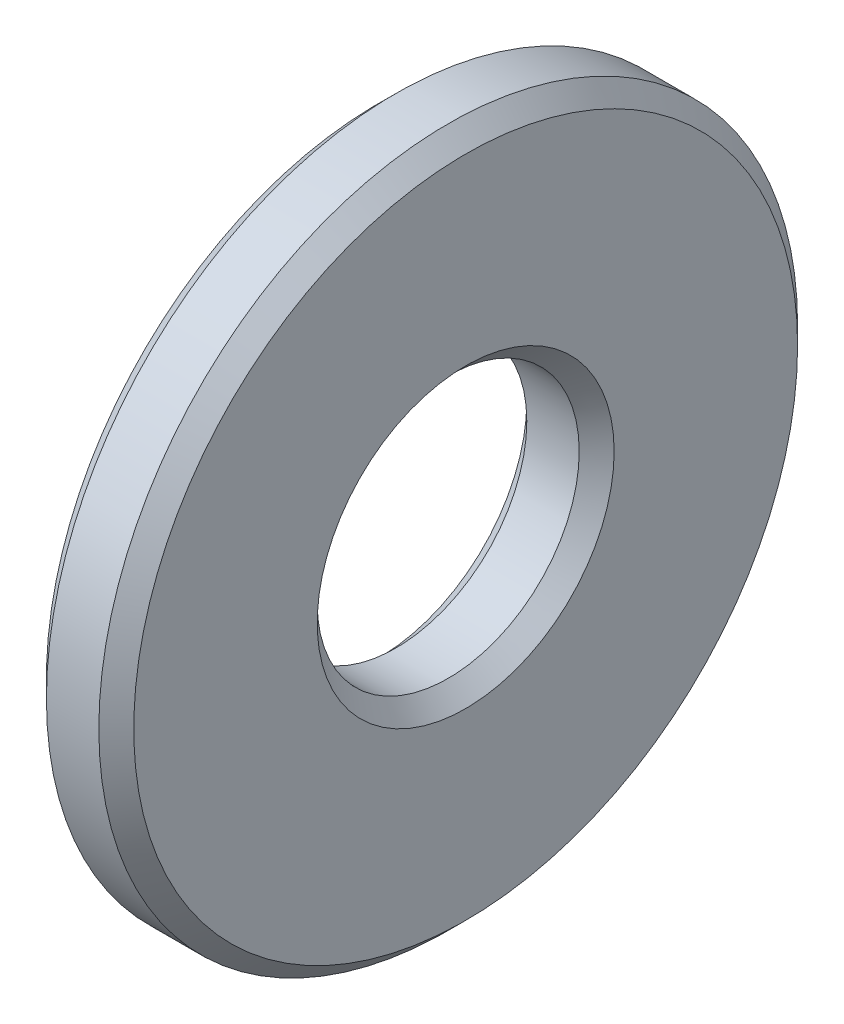
from build123d import *


with BuildPart() as part:
    # Sketch1 → Revolve1 (revolve)
    with BuildSketch(Plane.XY):
        Polygon((0, 3.8), (0, 1.7), (0.2, 1.5), (0.8, 1.5), (1, 1.7), (1, 3.8), (0.8, 4), (0.2, 4), align=None)
    revolve(axis=Axis((0, 0, 0), (1, 0, 0)))


solid = part.part
